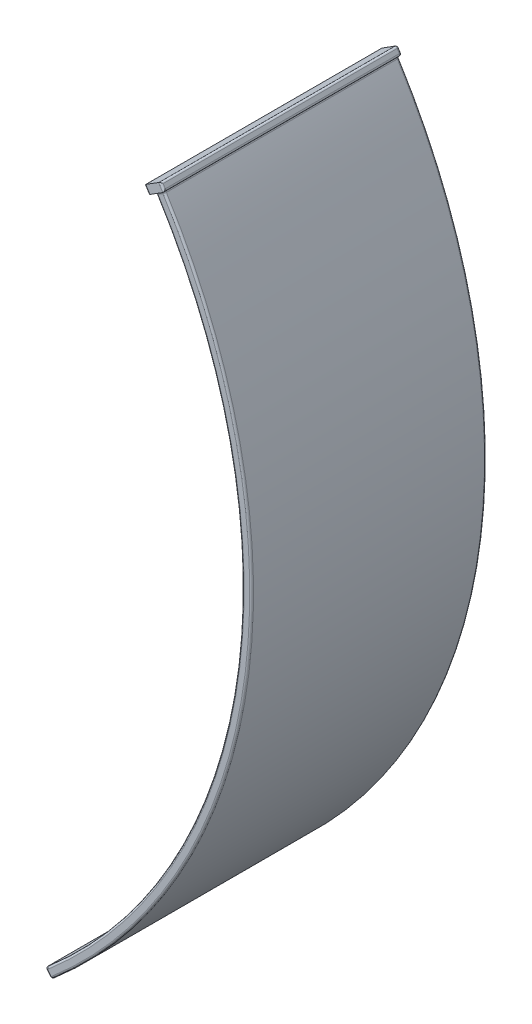
from build123d import *

# Parameters (mm, degrees)
SKETCH11_W              = 0.6
SKETCH11_H              = 15
SKETCH12_W              = 15
SKETCH12_H              = 0.6
BOSS_EXTRUDE1_DEPTH     = 0.2
SKETCH13_R              = 0.55
CUT_EXTRUDE1_DEPTH      = 36.424863097
CUT_EXTRUDE1_DEPTH_BACK = 9.964201433
SKETCH14_W              = 1.2
SKETCH14_H              = 15.2
BOSS_EXTRUDE2_DEPTH     = 0.5
FILLET1_R               = 0.12


with BuildPart() as part:
    # Sweep1: sweep along a path in Sketch7
    with BuildLine(Plane.XY) as sweep1_path:
        ThreePointArc((12.832156868, 1.661937028), (17.974752885, -22.779601272), (5.915655903, -44.652261565))
    # Sketch11 → Sweep1 (sweep)
    with BuildSketch(Plane(origin=(0, -17.481848747, 0), x_dir=(1, 0, 0), z_dir=(0, 1, 0))):
        with Locations((18.66815125, 0)):
            Rectangle(SKETCH11_W, SKETCH11_H)
    sweep(path=sweep1_path.line)

    # Sketch12 → Boss-Extrude1 (add)
    with BuildSketch(Plane(origin=(-18.686960593, -16.10455616, 0), x_dir=(0, 0, 1), z_dir=(-0.757508036, -0.652825838, 0))):
        with Locations((0, -37.986339997)):
            Rectangle(SKETCH12_W, SKETCH12_H)
    extrude(amount=BOSS_EXTRUDE1_DEPTH)

    # Sketch13 → Cut-Extrude1 (cut, two sides)
    with BuildSketch(Plane(origin=(24.602616496, -28.547705405, 0), x_dir=(0.757508036, 0.652825838, 0), z_dir=(-0.652825838, 0.757508036, 0))) as cut_extrude1_sk:
        with Locations((-23.368993196, 4)):
            Circle(SKETCH13_R)
        with Locations((-23.368993196, -4)):
            Circle(SKETCH13_R)
    extrude(amount=CUT_EXTRUDE1_DEPTH, mode=Mode.SUBTRACT)
    extrude(cut_extrude1_sk.sketch, amount=-CUT_EXTRUDE1_DEPTH_BACK, mode=Mode.SUBTRACT)

    # Sketch14 → Boss-Extrude2 (add)
    with BuildSketch(Plane(origin=(2.905305624, -4.603278943, 0), x_dir=(0.845657103, 0.533726582, 0), z_dir=(-0.533726582, 0.845657103, 0))):
        with Locations((12.038624569, -0.1)):
            Rectangle(SKETCH14_W, SKETCH14_H)
    extrude(amount=BOSS_EXTRUDE2_DEPTH)

    # Fillet1
    fillet1_edges = [part.edges().sort_by_distance(p)[0] for p in [
        (17.974752885, -22.779601272, -7.5),
        (5.8399051, -44.717544149, -7.5),
        (6.231600603, -45.172048971, -7.5),
        (17.974752885, -22.779601272, 7.5),
        (6.231600603, -45.172048971, 7.5),
        (5.8399051, -44.717544149, 7.5),
        (5.960002048, -45.010079144, -7.5),
        (6.155849799, -45.237331555, 0),
        (5.960002048, -45.010079144, 7.5),
        (5.764154296, -44.782826733, 0),
        (18.568172144, -22.868221717, 7.5),
        (18.568172144, -22.868221717, -7.5),
        (6.478667421, -44.156701751, -4),
        (6.870447172, -44.61130433, -4),
        (6.478667421, -44.156701751, 4),
        (6.870447172, -44.61130433, 4),
        (12.832156868, 1.661937028, 0),
        (13.59324826, 2.142290952, 0.1),
        (13.459816615, 2.353705228, 7.7),
        (13.466399695, 2.062231965, -7.5),
        (12.705308302, 1.581878041, -7.5),
        (13.459816615, 2.353705228, -7.5),
        (12.578459737, 1.501819054, 0.1),
        (12.445028091, 1.713233329, -7.5),
        (13.085853999, 1.822055003, 7.5),
        (12.445028091, 1.713233329, 7.7),
        (13.326384969, 2.565119504, 0.1),
        (12.818990708, 2.244883554, -7.5),
        (12.311596446, 1.924647605, 0.1),
        (13.339551129, 1.982172977, 0),
    ]]
    fillet(fillet1_edges, radius=FILLET1_R)


solid = part.part
